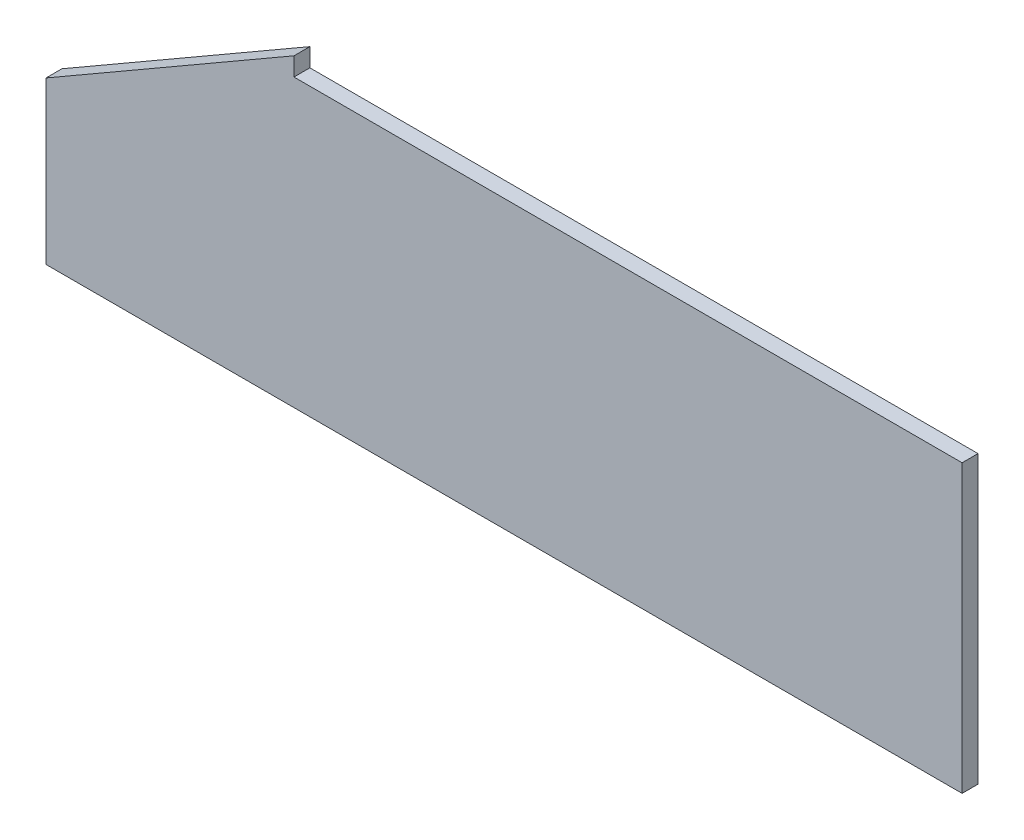
from build123d import *

# Parameters (mm, degrees)
EXTRUDE1_DEPTH = 10


with BuildPart() as part:
    # Sketch3 → Extrude1 (new body)
    with BuildSketch(Plane.XY):
        Polygon((0, 101.55), (155.884572681, 191.55), (155.884572681, 180), (575.884572681, 180), (575.884572681, 0), (0, 0), align=None)
    extrude(amount=EXTRUDE1_DEPTH)


solid = part.part
